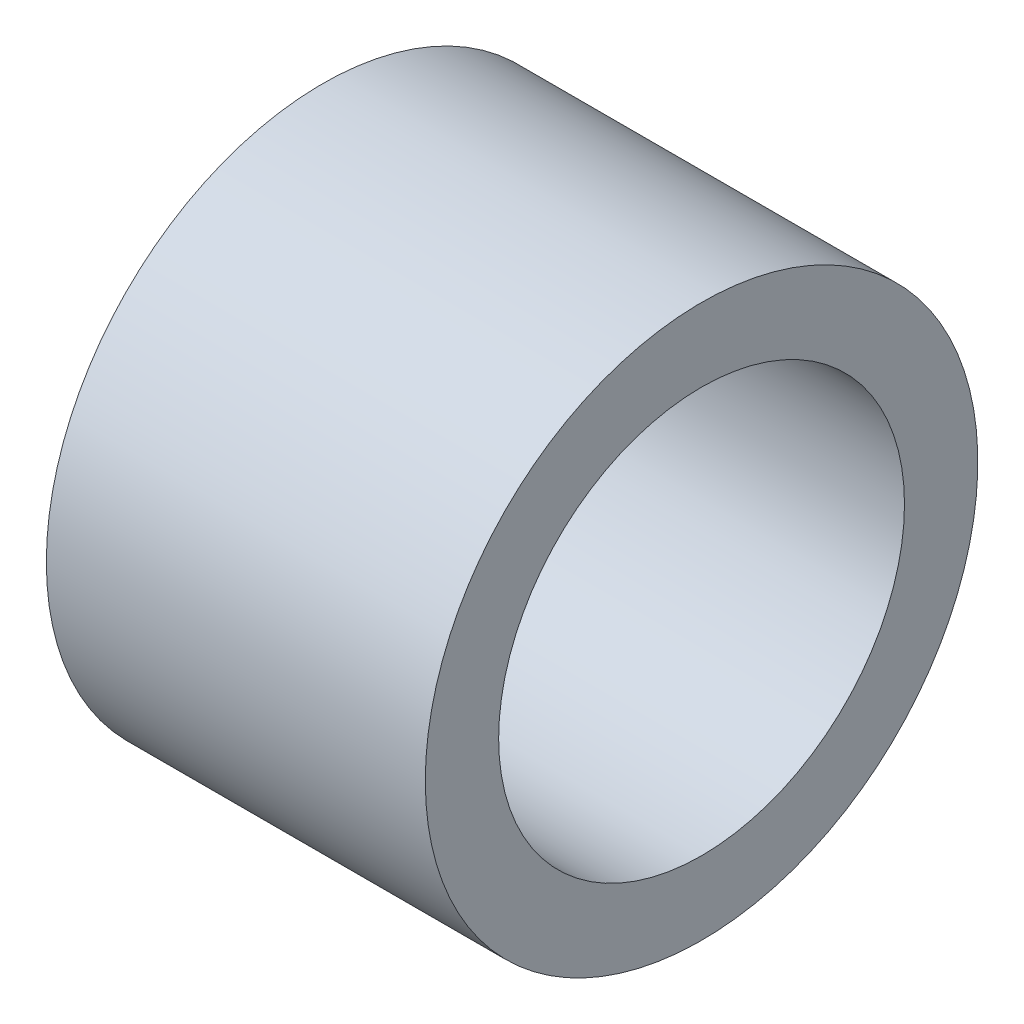
from build123d import *

# Parameters (mm, degrees)
SKETCH1_W = 7.75
SKETCH1_H = 1.5


with BuildPart() as part:
    # Sketch1 → Revolve1 (revolve)
    with BuildSketch(Plane(origin=(0, 0, 0), x_dir=(1, 0, 0), z_dir=(0, 1, 0))):
        with Locations((3.875, -4.9)):
            Rectangle(SKETCH1_W, SKETCH1_H)
    revolve(axis=Axis((0, 0, 0), (1, 0, 0)))


solid = part.part
